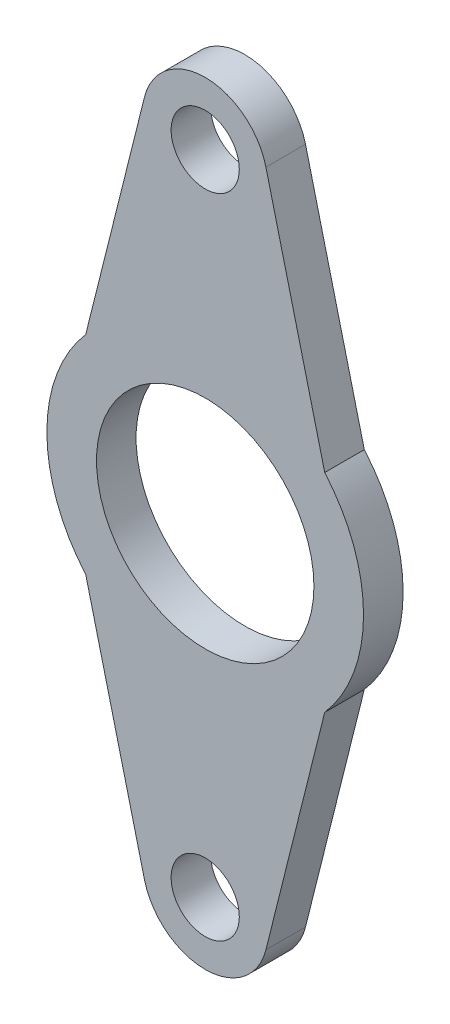
from build123d import *

# Parameters (mm, degrees)
SKETCH1_R           = 5.4689375
SKETCH1_R_2         = 17.441957863
BOSS_EXTRUDE1_DEPTH = 6.35


with BuildPart() as part:
    # Sketch1 → Boss-Extrude1 (new body)
    with BuildSketch(Plane.XY):
        with BuildLine():
            Line((19.172131573, 16.661013503), (9.740891327, 54.369598862))
            ThreePointArc((9.740891327, 54.369598862), (0, 61.974255991), (-9.740891326, 54.369598862))
            Line((-9.740891327, 54.369598862), (-19.172131573, 16.661013503))
            ThreePointArc((-19.172131573, 16.661013503), (-25.4, 0), (-19.172131573, -16.661013503))
            Line((-19.172131573, -16.661013503), (-9.740891327, -54.369598862))
            ThreePointArc((-9.740891326, -54.369598862), (0, -61.974255991), (9.740891327, -54.369598862))
            Line((9.740891327, -54.369598862), (19.172131573, -16.661013503))
            ThreePointArc((19.172131573, -16.661013503), (25.4, 0), (19.172131573, 16.661013503))
        make_face()
        with Locations((0, 51.933318491)):
            Circle(SKETCH1_R, mode=Mode.SUBTRACT)
        Circle(SKETCH1_R_2, mode=Mode.SUBTRACT)
        with Locations((0, -51.933318491)):
            Circle(SKETCH1_R, mode=Mode.SUBTRACT)
    extrude(amount=BOSS_EXTRUDE1_DEPTH)


solid = part.part
